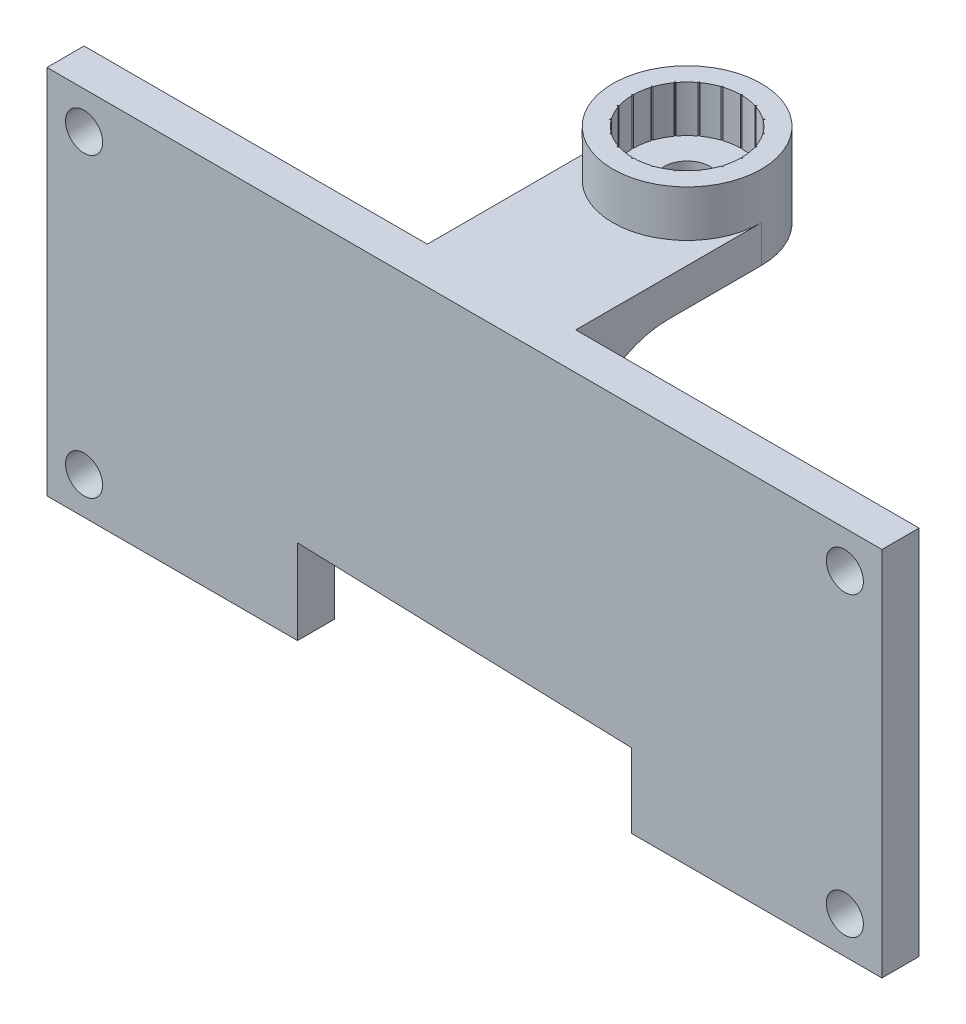
from build123d import *

# Parameters (mm, degrees)
SKETCH1_R           = 4
BOSS_EXTRUDE1_DEPTH = 2.5
BOSS_EXTRUDE5_DEPTH = 2
SKETCH10_R          = 1
BOSS_EXTRUDE6_DEPTH = 2
FILLET1_R           = 5
SKETCH11_R          = 1.25
CUT_EXTRUDE1_DEPTH  = 12


with BuildPart() as part:
    # Sketch1 → Boss-Extrude1 (new body)
    with BuildSketch(Plane(origin=(0, 0, 0), x_dir=(1, 0, 0), z_dir=(0, 1, 0))):
        with Locations((-36.385139863, -3.349743035)):
            Circle(SKETCH1_R)
        with BuildLine():
            Line((-36.385139863, -0.349743035), (-36.427751557, -0.423548653))
            ThreePointArc((-36.427751557, -0.423548653), (-36.842946049, -0.459268538), (-37.248857528, -0.553599062))
            Line((-37.248857528, -0.553599062), (-37.312190847, -0.496573486))
            Line((-37.312190847, -0.496573486), (-37.329909785, -0.579934537))
            ThreePointArc((-37.329909785, -0.579934537), (-37.713745161, -0.742208321), (-38.070640183, -0.957355526))
            Line((-38.070640183, -0.957355526), (-38.14849562, -0.922692052))
            Line((-38.14849562, -0.922692052), (-38.139587351, -1.007448576))
            ThreePointArc((-38.139587351, -1.007448576), (-38.454491129, -1.28039177), (-38.727434323, -1.595295548))
            Line((-38.727434323, -1.595295548), (-38.812190847, -1.586387278))
            Line((-38.812190847, -1.586387278), (-38.777527372, -1.664242716))
            ThreePointArc((-38.777527372, -1.664242716), (-38.992674577, -2.021137738), (-39.154948361, -2.404973114))
            Line((-39.154948361, -2.404973114), (-39.238309412, -2.422692052))
            Line((-39.238309412, -2.422692052), (-39.181283836, -2.486025371))
            ThreePointArc((-39.181283836, -2.486025371), (-39.27561436, -2.89193685), (-39.311334246, -3.307131342))
            Line((-39.311334246, -3.307131342), (-39.385139863, -3.349743035))
            Line((-39.385139863, -3.349743035), (-39.311334246, -3.392354728))
            ThreePointArc((-39.311334246, -3.392354728), (-39.27561436, -3.80754922), (-39.181283836, -4.2134607))
            Line((-39.181283836, -4.2134607), (-39.238309412, -4.276794018))
            Line((-39.238309412, -4.276794018), (-39.154948361, -4.294512957))
            ThreePointArc((-39.154948361, -4.294512957), (-38.992674577, -4.678348332), (-38.777527372, -5.035243354))
            Line((-38.777527372, -5.035243354), (-38.812190847, -5.113098792))
            Line((-38.812190847, -5.113098792), (-38.727434323, -5.104190522))
            ThreePointArc((-38.727434323, -5.104190522), (-38.454491129, -5.419094301), (-38.139587351, -5.692037494))
            Line((-38.139587351, -5.692037494), (-38.14849562, -5.776794018))
            Line((-38.14849562, -5.776794018), (-38.070640183, -5.742130544))
            ThreePointArc((-38.070640183, -5.742130544), (-37.713745161, -5.957277749), (-37.329909785, -6.119551533))
            Line((-37.329909785, -6.119551533), (-37.312190847, -6.202912584))
            Line((-37.312190847, -6.202912584), (-37.248857528, -6.145887008))
            ThreePointArc((-37.248857528, -6.145887008), (-36.842946049, -6.240217532), (-36.427751557, -6.275937417))
            Line((-36.427751557, -6.275937417), (-36.385139863, -6.349743035))
            Line((-36.385139863, -6.349743035), (-36.34252817, -6.275937417))
            ThreePointArc((-36.34252817, -6.275937417), (-35.927333678, -6.240217532), (-35.521422199, -6.145887008))
            Line((-35.521422199, -6.145887008), (-35.45808888, -6.202912584))
            Line((-35.45808888, -6.202912584), (-35.440369942, -6.119551533))
            ThreePointArc((-35.440369942, -6.119551533), (-35.056534566, -5.957277749), (-34.699639544, -5.742130544))
            Line((-34.699639544, -5.742130544), (-34.621784107, -5.776794018))
            Line((-34.621784107, -5.776794018), (-34.630692376, -5.692037494))
            ThreePointArc((-34.630692376, -5.692037494), (-34.315788598, -5.419094301), (-34.042845404, -5.104190522))
            Line((-34.042845404, -5.104190522), (-33.95808888, -5.113098792))
            Line((-33.95808888, -5.113098792), (-33.992752354, -5.035243354))
            ThreePointArc((-33.992752354, -5.035243354), (-33.77760515, -4.678348332), (-33.615331365, -4.294512957))
            Line((-33.615331365, -4.294512957), (-33.531970315, -4.276794018))
            Line((-33.531970315, -4.276794018), (-33.588995891, -4.2134607))
            ThreePointArc((-33.588995891, -4.2134607), (-33.494665367, -3.80754922), (-33.458945481, -3.392354728))
            Line((-33.458945481, -3.392354728), (-33.385139863, -3.349743035))
            Line((-33.385139863, -3.349743035), (-33.458945481, -3.307131342))
            ThreePointArc((-33.458945481, -3.307131342), (-33.494665367, -2.89193685), (-33.588995891, -2.486025371))
            Line((-33.588995891, -2.486025371), (-33.531970315, -2.422692052))
            Line((-33.531970315, -2.422692052), (-33.615331365, -2.404973114))
            ThreePointArc((-33.615331365, -2.404973114), (-33.77760515, -2.021137738), (-33.992752354, -1.664242716))
            Line((-33.992752354, -1.664242716), (-33.95808888, -1.586387278))
            Line((-33.95808888, -1.586387278), (-34.042845404, -1.595295548))
            ThreePointArc((-34.042845404, -1.595295548), (-34.315788598, -1.28039177), (-34.630692376, -1.007448576))
            Line((-34.630692376, -1.007448576), (-34.621784107, -0.922692052))
            Line((-34.621784107, -0.922692052), (-34.699639544, -0.957355526))
            ThreePointArc((-34.699639544, -0.957355526), (-35.056534566, -0.742208321), (-35.440369942, -0.579934537))
            Line((-35.440369942, -0.579934537), (-35.45808888, -0.496573486))
            Line((-35.45808888, -0.496573486), (-35.521422199, -0.553599062))
            ThreePointArc((-35.521422199, -0.553599062), (-35.927333678, -0.459268538), (-36.34252817, -0.423548653))
            Line((-36.34252817, -0.423548653), (-36.385139863, -0.349743035))
        make_face(mode=Mode.SUBTRACT)
    extrude(amount=BOSS_EXTRUDE1_DEPTH)

    # Sketch2 → Boss-Extrude5 (add)
    with BuildSketch(Plane.XZ):
        with BuildLine():
            ThreePointArc((-40.385139863, 3.349743035), (-36.385139863, -0.650256965), (-32.385139863, 3.349743035))
            Line((-32.385139863, 3.349743035), (-32.385139863, 13.349743035))
            Line((-32.385139863, 13.349743035), (-40.385139863, 13.349743035))
            Line((-40.385139863, 13.349743035), (-40.385139863, 3.349743035))
        make_face()
    extrude(amount=BOSS_EXTRUDE5_DEPTH)

    # Sketch10 → Boss-Extrude6 (add)
    with BuildSketch(Plane.XY.offset(13.349743035)):
        Polygon((-13.885139863, 0), (-58.885139863, 0), (-58.885139863, -20), (-45.380774313, -20), (-45.380774313, -15.439425839), (-27.389505414, -16), (-27.389505414, -20), (-13.885139863, -20), align=None)
        with Locations((-56.885139863, -18)):
            Circle(SKETCH10_R, mode=Mode.SUBTRACT)
        with Locations((-15.885139863, -18)):
            Circle(SKETCH10_R, mode=Mode.SUBTRACT)
        with Locations((-56.885139863, -2)):
            Circle(SKETCH10_R, mode=Mode.SUBTRACT)
        with Locations((-15.885139863, -2)):
            Circle(SKETCH10_R, mode=Mode.SUBTRACT)
    extrude(amount=BOSS_EXTRUDE6_DEPTH)

    # Fillet1
    fillet1_edges = [part.edges().sort_by_distance(p)[0] for p in [
        (-36.385139863, -2, 13.349743035),
    ]]
    fillet(fillet1_edges, radius=FILLET1_R)

    # Sketch11 → Cut-Extrude1 (cut)
    with BuildSketch(Plane.XZ.offset(2)):
        with Locations((-36.385139863, 3.349743035)):
            Circle(SKETCH11_R)
    extrude(amount=-CUT_EXTRUDE1_DEPTH, mode=Mode.SUBTRACT)


solid = part.part
